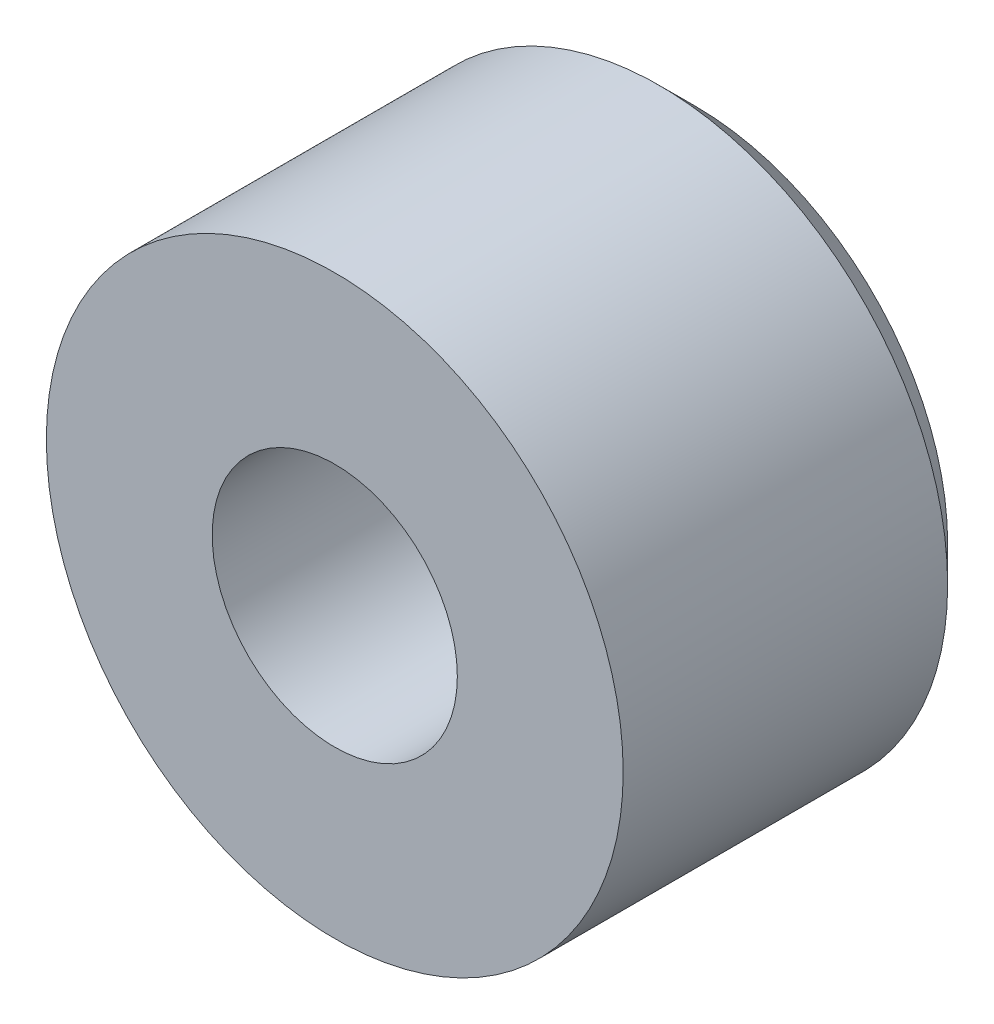
from build123d import *

# Parameters (mm, degrees)
SKETCH1_R           = 4
SKETCH1_R_2         = 1.7
BOSS_EXTRUDE1_DEPTH = 5
CHAMFER1_SIZE       = 0.5


with BuildPart() as part:
    # Sketch1 → Boss-Extrude1 (new body)
    with BuildSketch(Plane.XY):
        Circle(SKETCH1_R)
        Circle(SKETCH1_R_2, mode=Mode.SUBTRACT)
    extrude(amount=BOSS_EXTRUDE1_DEPTH)

    # Chamfer1
    chamfer1_edges = [part.edges().sort_by_distance(p)[0] for p in [
        (-4, 0, 0),
        (-1.7, 0, 0),
    ]]
    chamfer(chamfer1_edges, length=CHAMFER1_SIZE)


solid = part.part
